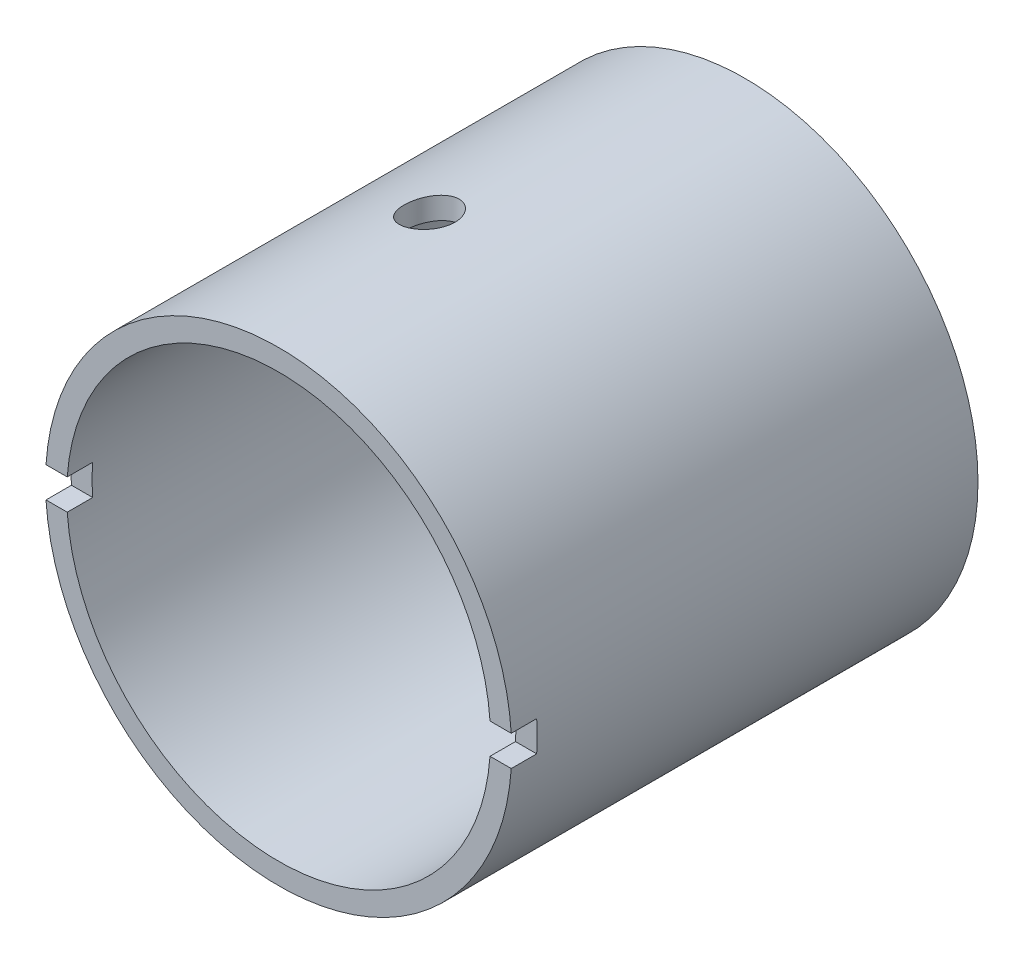
from build123d import *

# Parameters (mm, degrees)
SKETCH1_R           = 27.5
SKETCH1_R_2         = 25
BOSS_EXTRUDE1_DEPTH = 55
SKETCH2_R           = 1.6
BOSS_EXTRUDE2_DEPTH = 2
CUT_EXTRUDE1_START  = 55
SKETCH3_W           = 60.535746445
SKETCH3_H           = 3.6
CUT_EXTRUDE1_DEPTH  = 3
SKETCH4_R           = 3
CUT_EXTRUDE2_DEPTH  = 28.5


with BuildPart() as part:
    # Sketch1 → Boss-Extrude1 (new body)
    with BuildSketch(Plane.XY):
        Circle(SKETCH1_R)
        Circle(SKETCH1_R_2, mode=Mode.SUBTRACT)
    extrude(amount=BOSS_EXTRUDE1_DEPTH)

    # Sketch2 → Boss-Extrude2 (add)
    with BuildSketch(Plane.XY):
        with BuildLine():
            Line((-20, 4.1), (-26.124079623, 4.1))
            Line((-26.124079623, 4.1), (-26.124079623, -4.1))
            Line((-26.124079623, -4.1), (-20, -4.1))
            ThreePointArc((-20, -4.1), (-15.9, 0), (-20, 4.1))
        make_face()
        with Locations((-20, 0)):
            Circle(SKETCH2_R, mode=Mode.SUBTRACT)
        with BuildLine():
            Line((26.124079623, -4.1), (20, -4.1))
            ThreePointArc((20, -4.1), (15.9, 0), (20, 4.1))
            Line((20, 4.1), (26.124079623, 4.1))
            Line((26.124079623, 4.1), (26.124079623, -4.1))
        make_face()
        with Locations((20, 0)):
            Circle(SKETCH2_R, mode=Mode.SUBTRACT)
    extrude(amount=BOSS_EXTRUDE2_DEPTH)

    # Sketch3 → Cut-Extrude1 (cut)
    with BuildSketch(Plane.XY.offset(CUT_EXTRUDE1_START)):
        with Locations((1.235423396, 0)):
            Rectangle(SKETCH3_W, SKETCH3_H)
    extrude(amount=-CUT_EXTRUDE1_DEPTH, mode=Mode.SUBTRACT)

    # Sketch4 → Cut-Extrude2 (cut, through all)
    with BuildSketch(Plane(origin=(0, 0, 0), x_dir=(1, 0, 0), z_dir=(0, 1, 0))):
        with Locations((-5.5, -31.7)):
            Circle(SKETCH4_R)
    extrude(amount=CUT_EXTRUDE2_DEPTH, mode=Mode.SUBTRACT)


solid = part.part
